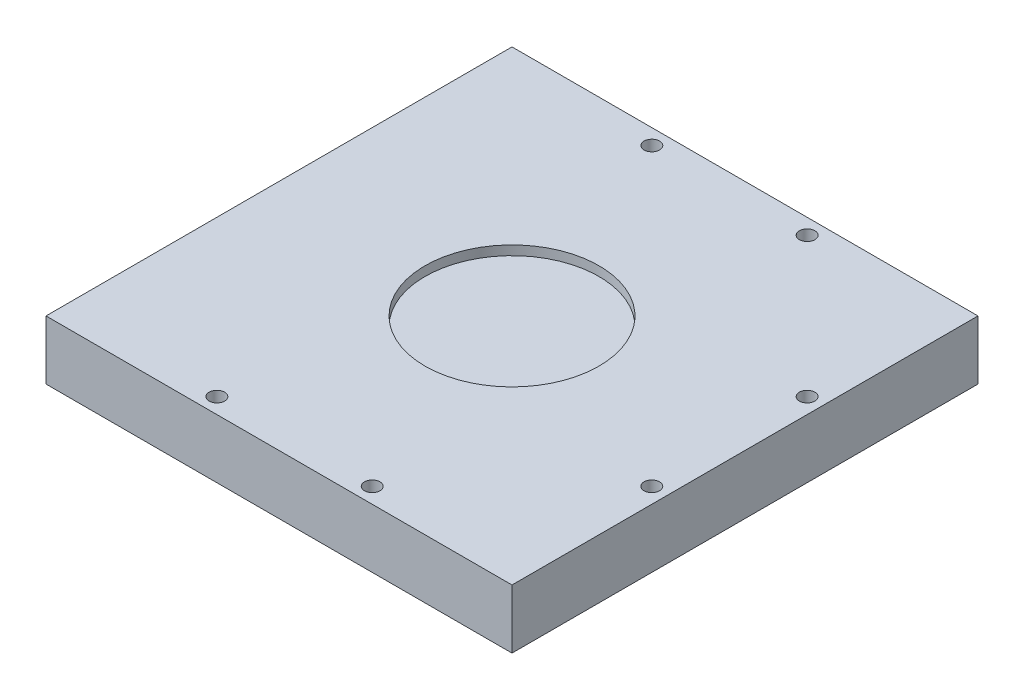
from build123d import *

# Parameters (mm, degrees)
SKETCH1_W           = 150
SKETCH1_H           = 150
BOSS_EXTRUDE1_DEPTH = 19
SKETCH2_R           = 28
CUT_EXTRUDE1_DEPTH  = 3
SKETCH3_R           = 2.5
CUT_EXTRUDE2_DEPTH  = 5
CIRPATTERN1_COUNT   = 3
CIRPATTERN1_ANGLE   = 180


with BuildPart() as part:
    # Sketch1 → Boss-Extrude1 (new body)
    with BuildSketch(Plane(origin=(0, 0, 0), x_dir=(1, 0, 0), z_dir=(0, 1, 0))):
        with Locations((75, 75)):
            Rectangle(SKETCH1_W, SKETCH1_H)
    extrude(amount=BOSS_EXTRUDE1_DEPTH)

    # Sketch2 → Cut-Extrude1 (cut)
    with BuildSketch(Plane(origin=(0, 19, 0), x_dir=(1, 0, 0), z_dir=(0, 1, 0))):
        with Locations((75, 75)):
            Circle(SKETCH2_R)
    extrude(amount=-CUT_EXTRUDE1_DEPTH, mode=Mode.SUBTRACT)

    # Sketch3 → Cut-Extrude2 (cut)
    with BuildSketch(Plane(origin=(0, 19, 0), x_dir=(1, 0, 0), z_dir=(0, 1, 0))):
        with Locations((100, 5)):
            Circle(SKETCH3_R)
        with Locations((50, 5)):
            Circle(SKETCH3_R)
    cut_extrude2 = extrude(amount=-CUT_EXTRUDE2_DEPTH, mode=Mode.SUBTRACT)

    # CirPattern1: Cut-Extrude2 ×3 about axis
    cirpattern1_axis = Axis((75, 16, -75), (0, 1, 0))
    for i in range(1, CIRPATTERN1_COUNT):
        add(cut_extrude2.rotate(cirpattern1_axis, i * CIRPATTERN1_ANGLE / (CIRPATTERN1_COUNT - 1)), mode=Mode.SUBTRACT)


solid = part.part
